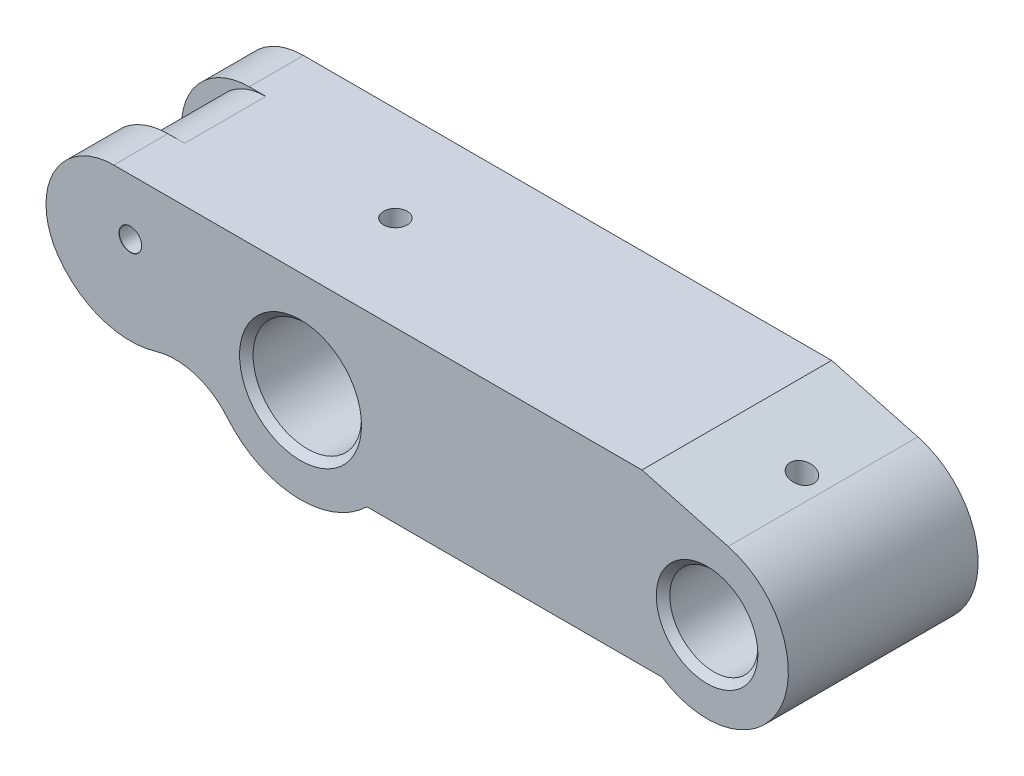
from build123d import *

# Parameters (mm, degrees)
EXTRUDE_1_DEPTH          = 14
CUT_EXTRUDE_1_DEPTH      = 6
SKETCH_3_R               = 8
CUT_EXTRUDE_2_DEPTH      = 1
CUT_EXTRUDE_2_DEPTH_BACK = 29
SKETCH_4_R               = 6.5
CUT_EXTRUDE_3_DEPTH      = 29
SKETCH_5_R               = 1.75
CUT_EXTRUDE_4_DEPTH      = 16
SKETCH_6_R               = 1.75
CUT_EXTRUDE_5_DEPTH      = 16.0000001
SKETCH_11_R              = 1.5
CUT_EXTRUDE_6_DEPTH      = 29.0000001
CHAMFER_1_SIZE           = 1


with BuildPart() as part:
    # 草图1 → 凸台-拉伸1 (new body, symmetric)
    with BuildSketch(Plane.XY):
        with BuildLine():
            Line((9.797958971, -10), (53.366750419, -10))
            ThreePointArc((53.366750419, -10), (70.93867824, -4.934097522), (63.105828541, 11.591109915))
            Line((63.105828541, 11.591109915), (50.383677548, 15))
            Line((50.383677548, 15), (-27.565507431, 15))
            ThreePointArc((-27.565507431, 15), (-36.443659616, 9.602001064), (-35.73696059, -0.764317242))
            ThreePointArc((-35.73696059, -0.764317242), (-29.353950463, -5.559863718), (-21.371826468, -5.720427806))
            ThreePointArc((-21.371826468, -5.720427806), (-15.596757504, -5.725786931), (-10.787686266, -8.923330377))
            ThreePointArc((-10.787686266, -8.923330377), (-0.731228007, -13.98089073), (9.797958971, -10))
        make_face()
    extrude(amount=EXTRUDE_1_DEPTH, both=True)

    # 草图2 → 切除-拉伸1 (cut, symmetric)
    with BuildSketch(Plane.XY):
        with BuildLine():
            Line((-25.114071484, 15), (-25.880172402, 19.294363036))
            Line((-25.880172402, 19.294363036), (-38.301734179, 16.64803031))
            Line((-38.301734179, 16.64803031), (-39.057829244, 0.337979629))
            Line((-39.057829244, 0.337979629), (-36.873567525, -9.914677417))
            Line((-36.873567525, -9.914677417), (-21.991683498, -16.836179697))
            Line((-21.991683498, -16.836179697), (-15.8349094, -12.46162968))
            Line((-15.8349094, -12.46162968), (-10.787686266, -8.923330377))
            ThreePointArc((-10.787686266, -8.923330377), (-15.290702499, -2.479910341), (-23.059900609, -1.282255262))
            ThreePointArc((-23.059900609, -1.282255262), (-33.319731944, 5.694068268), (-25.114071484, 15))
        make_face()
    extrude(amount=CUT_EXTRUDE_1_DEPTH, both=True, mode=Mode.SUBTRACT)

    # 草图3 → 切除-拉伸2 (cut, two sides)
    with BuildSketch(Plane.XY.offset(14)) as cut_extrude_2_sk:
        Circle(SKETCH_3_R)
    extrude(amount=CUT_EXTRUDE_2_DEPTH, mode=Mode.SUBTRACT)
    extrude(cut_extrude_2_sk.sketch, amount=-CUT_EXTRUDE_2_DEPTH_BACK, mode=Mode.SUBTRACT)

    # 草图4 → 切除-拉伸3 (cut, through all)
    with BuildSketch(Plane.XY.offset(14)):
        with Locations((60, 0)):
            Circle(SKETCH_4_R)
    extrude(amount=-CUT_EXTRUDE_3_DEPTH, mode=Mode.SUBTRACT)

    # 草图5 → 切除-拉伸4 (cut, through all)
    with BuildSketch(Plane(origin=(0, 0, 0), x_dir=(1, 0, 0), z_dir=(0, 1, 0))):
        Circle(SKETCH_5_R)
    extrude(amount=CUT_EXTRUDE_4_DEPTH, mode=Mode.SUBTRACT)

    # 草图6 → 切除-拉伸5 (cut, through all)
    with BuildSketch(Plane(origin=(0, 0, 0), x_dir=(1, 0, 0), z_dir=(0, 1, 0))):
        with Locations((60, 0)):
            Circle(SKETCH_6_R)
    extrude(amount=CUT_EXTRUDE_5_DEPTH, mode=Mode.SUBTRACT)

    # 草图10 → M4 螺纹孔的螺纹孔钻头1 (revolve, cut)
    with BuildSketch(Plane(origin=(-25.114071484, 6.729295173, 14), x_dir=(0, -1, 0), z_dir=(1, 0, 0))):
        Polygon((0, 0), (0, 8.991420021), (1.65, 8), (1.65, 0.025), (1.675, 0), align=None)
    hole_wizard_m4_1 = revolve(axis=Axis((-25.114071484, 6.729295173, 20.35), (0, 0, -1)), mode=Mode.SUBTRACT)

    # 镜向1: M4 螺纹孔的螺纹孔钻头1 across plane
    add(hole_wizard_m4_1.mirror(Plane.XY), mode=Mode.SUBTRACT)

    # 草图11 → 切除-拉伸6 (cut, through all)
    with BuildSketch(Plane.XY.offset(14)):
        with Locations((-25.114071484, 6.729295173)):
            Circle(SKETCH_11_R)
    extrude(amount=-CUT_EXTRUDE_6_DEPTH, mode=Mode.SUBTRACT)

    # 倒角1
    chamfer_1_edges = [part.edges().sort_by_distance(p)[0] for p in [
        (-8, 0, 14),
        (-8, 0, -14),
        (53.5, 0, -14),
        (53.5, 0, 14),
    ]]
    chamfer(chamfer_1_edges, length=CHAMFER_1_SIZE)


solid = part.part
